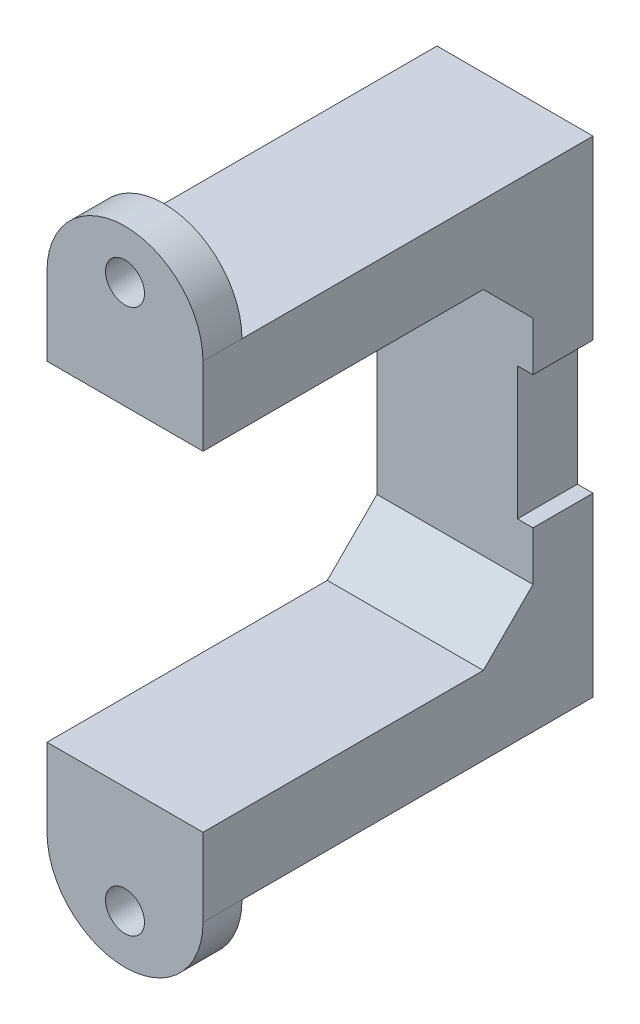
from build123d import *

# Parameters (mm, degrees)
SKETCH1_W               = 20
SKETCH1_H               = 50
BOSS_EXTRUDE2_DEPTH     = 62.3
CUT_EXTRUDE1_DEPTH      = 1
CUT_EXTRUDE1_DEPTH_BACK = 21
BOSS_EXTRUDE3_DEPTH     = 5
SKETCH6_R               = 2.5
CUT_EXTRUDE2_DEPTH      = 5
SKETCH7_W               = 2
SKETCH7_H               = 17
CUT_EXTRUDE3_DEPTH      = 10


with BuildPart() as part:
    # Sketch1 → Boss-Extrude2 (new body)
    with BuildSketch(Plane(origin=(0, 0, 0), x_dir=(1, 0, 0), z_dir=(0, 1, 0))):
        with Locations((-10, 25)):
            Rectangle(SKETCH1_W, SKETCH1_H)
    extrude(amount=BOSS_EXTRUDE2_DEPTH)

    # Sketch2 → Cut-Extrude1 (cut, two sides)
    with BuildSketch(Plane(origin=(0, 0, 0), x_dir=(0, 0, -1), z_dir=(1, 0, 0))) as cut_extrude1_sk:
        Polygon((0, 52.3), (35.936038969, 52.3), (42.3, 45.936038969), (42.3, 16.363961031), (35.936038969, 10), (0, 10), align=None)
    extrude(amount=CUT_EXTRUDE1_DEPTH, mode=Mode.SUBTRACT)
    extrude(cut_extrude1_sk.sketch, amount=-CUT_EXTRUDE1_DEPTH_BACK, mode=Mode.SUBTRACT)

    # Sketch5 → Boss-Extrude3 (add)
    with BuildSketch(Plane.XY):
        with BuildLine():
            Line((-20, 62.3), (0, 62.3))
            ThreePointArc((0, 62.3), (-10, 72.3), (-20, 62.3))
        make_face()
        with BuildLine():
            Line((-20, 0), (0, 0))
            ThreePointArc((0, 0), (-10, -10), (-20, 0))
        make_face()
    extrude(amount=-BOSS_EXTRUDE3_DEPTH)

    # Sketch6 → Cut-Extrude2 (cut)
    with BuildSketch(Plane(origin=(0, 0, -5), x_dir=(-1, 0, 0), z_dir=(0, 0, -1))):
        with Locations((10, 66.05)):
            Circle(SKETCH6_R)
        with Locations((10, -3.75)):
            Circle(SKETCH6_R)
    extrude(amount=-CUT_EXTRUDE2_DEPTH, mode=Mode.SUBTRACT)

    # Sketch7 → Cut-Extrude3 (cut)
    with BuildSketch(Plane(origin=(0, 0, -50), x_dir=(-1, 0, 0), z_dir=(0, 0, -1))):
        with Locations((1, 31.15)):
            Rectangle(SKETCH7_W, SKETCH7_H)
    extrude(amount=-CUT_EXTRUDE3_DEPTH, mode=Mode.SUBTRACT)


solid = part.part
